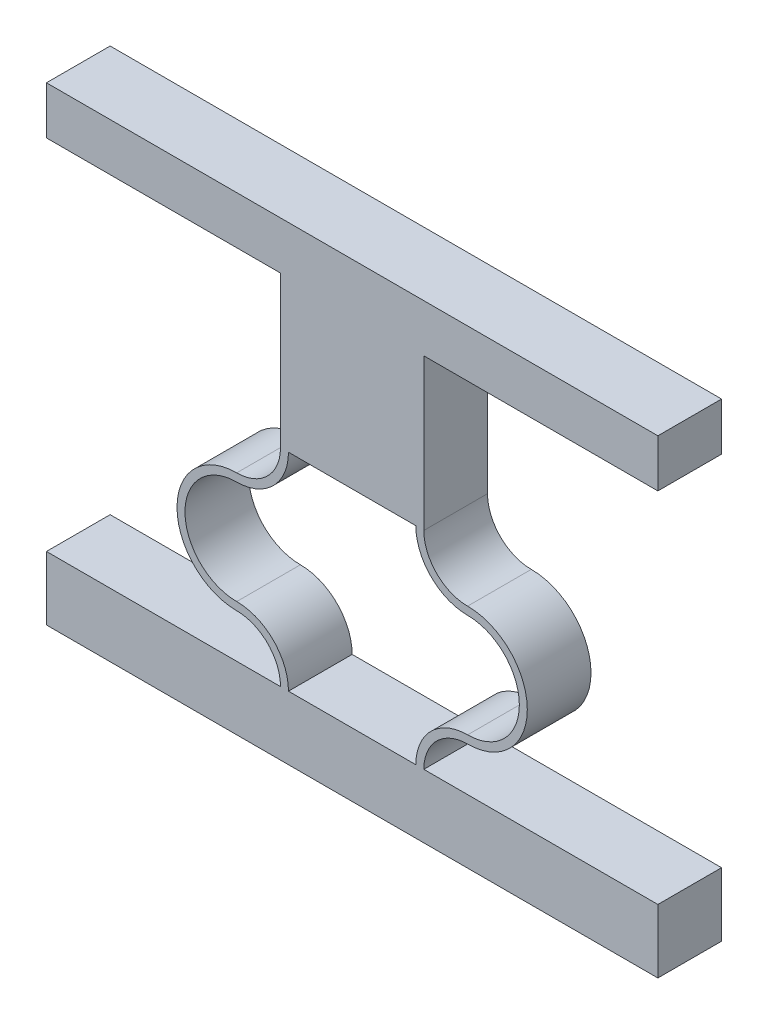
from build123d import *

# Parameters (mm, degrees)
BOSS_EXTRUDE1_DEPTH = 4
SKETCH4_W           = 1.000028655
SKETCH4_H           = 4
BOSS_EXTRUDE2_DEPTH = 1.5
SKETCH7_W           = 4
SKETCH7_H           = 4.491123012
SKETCH7_H_2         = 4
BOSS_EXTRUDE3_DEPTH = 4
MOVE_FACE1_BY       = 5
SKETCH8_W           = 38.400000218
SKETCH8_H           = 3
BOSS_EXTRUDE4_DEPTH = 4
CUT_EXTRUDE1_DEPTH  = 37.207145202
SKETCH11_W          = 5.000000006
SKETCH11_H          = 13.249999512
SKETCH11_W_2        = 5.000000005
CUT_EXTRUDE2_DEPTH  = 37.20714505


with BuildPart() as part:
    # Sketch1 → Boss-Extrude1 (new body)
    with BuildSketch(Plane.XY):
        with BuildLine():
            add(Edge.make_bspline(
                [(10.700014224, 14.741123012), (10.769414318, 14.738663695), (11.03310814, 14.727603281), (11.490614063, 14.697170592), (12.262749669, 14.614202549), (13.344934017, 14.437909286), (14.416347819, 14.207015891), (15.483183095, 13.956131655), (16.319838847, 13.766249034), (16.857815383, 13.652304096), (17.362886901, 13.553302991), (17.776414428, 13.479790745), (18.203500731, 13.412396588), (18.656257538, 13.353987061), (18.987768381, 13.3179099), (19.289919617, 13.293036934), (19.513652899, 13.276508776), (19.742348402, 13.265861771), (19.917436469, 13.255829602), (20.20131205, 13.251344917), (20.318835942, 13.249999512), (20.4, 13.249999512)],
                knots=[0.520196639, 0.520196639, 0.520196639, 0.520196639, 0.520196639, 0.53141408, 0.562828159, 0.594242235, 0.645597029, 0.708425214, 0.739839305, 0.771253396, 0.784217346, 0.797181296, 0.823109196, 0.838816246, 0.854523296, 0.870230336, 0.878083855, 0.885937375, 0.893790894, 0.901644413, 0.917351451, 0.917351451, 0.917351451, 0.917351451, 0.917351451], degree=4))
            Line((10.700014224, 14.741123012), (10.700014224, 15.991123012))
            Line((10.700014224, 15.991123012), (9.699985569, 15.991123012))
            Line((9.699985569, 15.991123012), (9.699985569, 14.741123012))
            add(Edge.make_bspline(
                [(0, 13.249999512), (0.081164058, 13.249999512), (0.199729304, 13.251344907), (0.473779629, 13.255829663), (0.709191365, 13.267868104), (1.033438356, 13.285149543), (1.35158977, 13.312755641), (1.750162777, 13.353987577), (2.192328474, 13.412395709), (2.7057608, 13.49221948), (3.305792882, 13.602949191), (4.002230953, 13.748490017), (4.916593693, 13.956132269), (5.983810028, 14.207015465), (7.054976456, 14.437909533), (8.137289789, 14.614202431), (8.909375138, 14.697170645), (9.366886361, 14.727603295), (9.630584373, 14.738663696), (9.699985569, 14.741123012)],
                knots=[0.082648549, 0.082648549, 0.082648549, 0.082648549, 0.082648549, 0.098355587, 0.106209106, 0.114062625, 0.129769664, 0.145476704, 0.161183754, 0.176890804, 0.202818704, 0.228746604, 0.260160695, 0.291574786, 0.354402971, 0.405757765, 0.437171841, 0.46858592, 0.479803371, 0.479803371, 0.479803371, 0.479803371, 0.479803371], degree=4))
            Line((0, 13.249999512), (-5.000000005, 13.249999512))
            Line((-5.000000005, 13.249999512), (-5.000000005, -4))
            Line((-5.000000005, -4), (25.400000005, -4))
            Line((25.400000005, -4), (25.400000005, 13.249999512))
            Line((25.400000005, 13.249999512), (20.4, 13.249999512))
        make_face()
        with BuildLine():
            Line((9.699985569, 14.491123012), (9.699985569, 13.241123012))
            add(Edge.make_bspline(
                [(0, 11.749999512), (0.081164058, 11.749999512), (0.199729304, 11.751344907), (0.473779629, 11.755829663), (0.709191365, 11.767868104), (1.033438356, 11.785149543), (1.35158977, 11.812755641), (1.750162777, 11.853987577), (2.192328474, 11.912395709), (2.7057608, 11.99221948), (3.305792882, 12.102949191), (4.002230953, 12.248490017), (4.916593693, 12.456132269), (5.983810028, 12.707015465), (7.054976456, 12.937909533), (8.137289789, 13.114202431), (8.909375138, 13.197170645), (9.366886361, 13.227603295), (9.630584373, 13.238663696), (9.699985569, 13.241123012)],
                knots=[0.082648549, 0.082648549, 0.082648549, 0.082648549, 0.082648549, 0.098355587, 0.106209106, 0.114062625, 0.129769664, 0.145476704, 0.161183754, 0.176890804, 0.202818704, 0.228746604, 0.260160695, 0.291574786, 0.354402971, 0.405757765, 0.437171841, 0.46858592, 0.479803371, 0.479803371, 0.479803371, 0.479803371, 0.479803371], degree=4))
            Line((0, 11.749999512), (0, 12.999999512))
            add(Edge.make_bspline(
                [(0, 12.999999512), (0.081164058, 12.999999512), (0.199729304, 13.001344907), (0.473779629, 13.005829663), (0.709191365, 13.017868104), (1.033438356, 13.035149543), (1.35158977, 13.062755641), (1.750162777, 13.103987577), (2.192328474, 13.162395709), (2.7057608, 13.24221948), (3.305792882, 13.352949191), (4.002230953, 13.498490017), (4.916593693, 13.706132269), (5.983810028, 13.957015465), (7.054976456, 14.187909533), (8.137289789, 14.364202431), (8.909375138, 14.447170645), (9.366886361, 14.477603295), (9.630584373, 14.488663696), (9.699985569, 14.491123012)],
                knots=[0.082648549, 0.082648549, 0.082648549, 0.082648549, 0.082648549, 0.098355587, 0.106209106, 0.114062625, 0.129769664, 0.145476704, 0.161183754, 0.176890804, 0.202818704, 0.228746604, 0.260160695, 0.291574786, 0.354402971, 0.405757765, 0.437171841, 0.46858592, 0.479803371, 0.479803371, 0.479803371, 0.479803371, 0.479803371], degree=4))
        make_face(mode=Mode.SUBTRACT)
        with BuildLine():
            Line((10.700014224, 13.241123012), (10.700014224, 14.491123012))
            add(Edge.make_bspline(
                [(10.700014224, 14.491123012), (10.769414318, 14.488663695), (11.03310814, 14.477603281), (11.490614063, 14.447170592), (12.262749669, 14.364202549), (13.344934017, 14.187909286), (14.416347819, 13.957015891), (15.483183095, 13.706131655), (16.319838847, 13.516249034), (16.857815383, 13.402304096), (17.362886901, 13.303302991), (17.776414428, 13.229790745), (18.203500731, 13.162396588), (18.656257538, 13.103987061), (18.987768381, 13.0679099), (19.289919617, 13.043036934), (19.513652899, 13.026508776), (19.742348402, 13.015861771), (19.917436469, 13.005829602), (20.20131205, 13.001344917), (20.318835942, 12.999999512), (20.4, 12.999999512)],
                knots=[0.520196639, 0.520196639, 0.520196639, 0.520196639, 0.520196639, 0.53141408, 0.562828159, 0.594242235, 0.645597029, 0.708425214, 0.739839305, 0.771253396, 0.784217346, 0.797181296, 0.823109196, 0.838816246, 0.854523296, 0.870230336, 0.878083855, 0.885937375, 0.893790894, 0.901644413, 0.917351451, 0.917351451, 0.917351451, 0.917351451, 0.917351451], degree=4))
            Line((20.4, 12.999999512), (20.4, 11.749999512))
            add(Edge.make_bspline(
                [(10.700014224, 13.241123012), (10.769414318, 13.238663695), (11.03310814, 13.227603281), (11.490614063, 13.197170592), (12.262749669, 13.114202549), (13.344934017, 12.937909286), (14.416347819, 12.707015891), (15.483183095, 12.456131655), (16.319838847, 12.266249034), (16.857815383, 12.152304096), (17.362886901, 12.053302991), (17.776414428, 11.979790745), (18.203500731, 11.912396588), (18.656257538, 11.853987061), (18.987768381, 11.8179099), (19.289919617, 11.793036934), (19.513652899, 11.776508776), (19.742348402, 11.765861771), (19.917436469, 11.755829602), (20.20131205, 11.751344917), (20.318835942, 11.749999512), (20.4, 11.749999512)],
                knots=[0.520196639, 0.520196639, 0.520196639, 0.520196639, 0.520196639, 0.53141408, 0.562828159, 0.594242235, 0.645597029, 0.708425214, 0.739839305, 0.771253396, 0.784217346, 0.797181296, 0.823109196, 0.838816246, 0.854523296, 0.870230336, 0.878083855, 0.885937375, 0.893790894, 0.901644413, 0.917351451, 0.917351451, 0.917351451, 0.917351451, 0.917351451], degree=4))
        make_face(mode=Mode.SUBTRACT)
        with BuildLine():
            Line((0, 0), (0, 11.499999512))
            add(Edge.make_bspline(
                [(0, 11.499999512), (0.081164058, 11.499999512), (0.199729304, 11.501344907), (0.473779629, 11.505829663), (0.709191365, 11.517868104), (1.033438356, 11.535149543), (1.35158977, 11.562755641), (1.750162777, 11.603987577), (2.192328474, 11.662395709), (2.7057608, 11.74221948), (3.305792882, 11.852949191), (4.002230953, 11.998490017), (4.916593693, 12.206132269), (5.983810028, 12.457015465), (7.054976456, 12.687909533), (8.137289789, 12.864202431), (8.909375138, 12.947170645), (9.366886361, 12.977603295), (9.630584373, 12.988663696), (9.699985569, 12.991123012)],
                knots=[0.082648549, 0.082648549, 0.082648549, 0.082648549, 0.082648549, 0.098355587, 0.106209106, 0.114062625, 0.129769664, 0.145476704, 0.161183754, 0.176890804, 0.202818704, 0.228746604, 0.260160695, 0.291574786, 0.354402971, 0.405757765, 0.437171841, 0.46858592, 0.479803371, 0.479803371, 0.479803371, 0.479803371, 0.479803371], degree=4))
            ThreePointArc((9.699985569, 12.991123012), (8.891402518, 11.052320391), (6.949999896, 10.25))
            ThreePointArc((6.949999896, 10.25), (3.199999896, 6.5), (6.949999896, 2.75))
            ThreePointArc((6.949999896, 2.75), (8.894543545, 1.944543648), (9.699999896, 0))
            Line((9.699999896, 0), (0, 0))
        make_face(mode=Mode.SUBTRACT)
        with BuildLine():
            ThreePointArc((6.949999896, 9.75), (9.248096935, 10.701902961), (10.199999896, 13))
            ThreePointArc((10.199999896, 13), (11.151902857, 10.701902961), (13.449999896, 9.75))
            ThreePointArc((13.449999896, 9.75), (16.699999896, 6.5), (13.449999896, 3.25))
            ThreePointArc((13.449999896, 3.25), (11.151902857, 2.298097039), (10.199999896, 0))
            ThreePointArc((10.199999896, 0), (9.248096935, 2.298097039), (6.949999896, 3.25))
            ThreePointArc((6.949999896, 3.25), (3.699999896, 6.5), (6.949999896, 9.75))
        make_face(mode=Mode.SUBTRACT)
        with BuildLine():
            ThreePointArc((13.449999896, 10.25), (11.508597274, 11.052320391), (10.700014224, 12.991123012))
            add(Edge.make_bspline(
                [(10.700014224, 12.991123012), (10.769414318, 12.988663695), (11.03310814, 12.977603281), (11.490614063, 12.947170592), (12.262749669, 12.864202549), (13.344934017, 12.687909286), (14.416347819, 12.457015891), (15.483183095, 12.206131655), (16.319838847, 12.016249034), (16.857815383, 11.902304096), (17.362886901, 11.803302991), (17.776414428, 11.729790745), (18.203500731, 11.662396588), (18.656257538, 11.603987061), (18.987768381, 11.5679099), (19.289919617, 11.543036934), (19.513652899, 11.526508776), (19.742348402, 11.515861771), (19.917436469, 11.505829602), (20.20131205, 11.501344917), (20.318835942, 11.499999512), (20.4, 11.499999512)],
                knots=[0.520196639, 0.520196639, 0.520196639, 0.520196639, 0.520196639, 0.53141408, 0.562828159, 0.594242235, 0.645597029, 0.708425214, 0.739839305, 0.771253396, 0.784217346, 0.797181296, 0.823109196, 0.838816246, 0.854523296, 0.870230336, 0.878083855, 0.885937375, 0.893790894, 0.901644413, 0.917351451, 0.917351451, 0.917351451, 0.917351451, 0.917351451], degree=4))
            Line((20.4, 11.499999512), (20.4, 0))
            Line((20.4, 0), (10.699999896, 0))
            ThreePointArc((10.699999896, 0), (11.505456248, 1.944543648), (13.449999896, 2.75))
            ThreePointArc((13.449999896, 2.75), (17.199999896, 6.5), (13.449999896, 10.25))
        make_face(mode=Mode.SUBTRACT)
    extrude(amount=BOSS_EXTRUDE1_DEPTH)

    # Sketch4 → Boss-Extrude2 (add)
    with BuildSketch(Plane(origin=(0, 15.991123012, 0), x_dir=(1, 0, 0), z_dir=(0, 1, 0))):
        with Locations((10.199999896, -2)):
            Rectangle(SKETCH4_W, SKETCH4_H)
    extrude(amount=BOSS_EXTRUDE2_DEPTH)

    # Split2
    split(bisect_by=Plane(origin=(10.199999896, 0, 0), x_dir=(0, -1, 0), z_dir=(-1, 0, 0)), keep=Keep.BOTTOM)

    # Sketch7 → Boss-Extrude3 (add)
    with BuildSketch(Plane.ZY.offset(-10.199999896)):
        with Locations((2, 15.245561506)):
            Rectangle(SKETCH7_W, SKETCH7_H)
        with Locations((2, -2)):
            Rectangle(SKETCH7_W, SKETCH7_H_2)
    extrude(amount=BOSS_EXTRUDE3_DEPTH)

    # Mirror2: part across plane


with BuildPart() as part_1:
    add(part.part)
    add(part.part.mirror(Plane.ZY.offset(-6.199999896)))

    # Move Face1: a face moved outward by 5.0
    extrude(part_1.faces().sort_by_distance((6.199999896, 17.491123012, 2))[0], amount=MOVE_FACE1_BY, dir=(0, 1, 0))

    # Sketch8 → Boss-Extrude4 (add)
    with BuildSketch(Plane.XY.offset(4)):
        with Locations((6.199999896, 23.991123012)):
            Rectangle(SKETCH8_W, SKETCH8_H)
    extrude(amount=-BOSS_EXTRUDE4_DEPTH)

    # Sketch10 → Cut-Extrude1 (cut, through all)
    with BuildSketch(Plane.XY.offset(4)):
        Polygon((10.700014224, 12.991123012), (10.700014224, 13.241123012), (10.700014224, 14.491123012), (10.700014224, 14.741123012), (20.4, 14.741123012), (20.4, 11.499999512), (15.435396156, 11.499999512), align=None)
        with BuildLine():
            Line((1.699985569, 14.491123012), (1.699985569, 14.741123012))
            add(Edge.make_bspline(
                [(1.699985569, 14.741123012), (1.630585475, 14.738663695), (1.366891652, 14.727603281), (0.909385729, 14.697170592), (0.137250123, 14.614202549), (-0.944934224, 14.437909286), (-2.016348027, 14.207015891), (-3.083183302, 13.956131655), (-3.919839055, 13.766249034), (-4.45781559, 13.652304096), (-4.962887108, 13.553302991), (-5.376414636, 13.479790745), (-5.803500939, 13.412396588), (-6.256257745, 13.353987061), (-6.587768589, 13.3179099), (-6.889919824, 13.293036934), (-7.113653107, 13.276508776), (-7.342348609, 13.265861771), (-7.517436676, 13.255829602), (-7.801312257, 13.251344917), (-7.91883615, 13.249999512), (-8.000000207, 13.249999512)],
                knots=[0.520196639, 0.520196639, 0.520196639, 0.520196639, 0.520196639, 0.53141408, 0.562828159, 0.594242235, 0.645597029, 0.708425214, 0.739839305, 0.771253396, 0.784217346, 0.797181296, 0.823109196, 0.838816246, 0.854523296, 0.870230336, 0.878083855, 0.885937375, 0.893790894, 0.901644413, 0.917351451, 0.917351451, 0.917351451, 0.917351451, 0.917351451], degree=4))
            Line((-8.000000207, 13.249999512), (-8.000000207, 12.999999512))
            add(Edge.make_bspline(
                [(1.699985569, 14.491123012), (1.630585475, 14.488663695), (1.366891652, 14.477603281), (0.909385729, 14.447170592), (0.137250123, 14.364202549), (-0.944934224, 14.187909286), (-2.016348027, 13.957015891), (-3.083183302, 13.706131655), (-3.919839055, 13.516249034), (-4.45781559, 13.402304096), (-4.962887108, 13.303302991), (-5.376414636, 13.229790745), (-5.803500939, 13.162396588), (-6.256257745, 13.103987061), (-6.587768589, 13.0679099), (-6.889919824, 13.043036934), (-7.113653107, 13.026508776), (-7.342348609, 13.015861771), (-7.517436676, 13.005829602), (-7.801312257, 13.001344917), (-7.91883615, 12.999999512), (-8.000000207, 12.999999512)],
                knots=[0.520196639, 0.520196639, 0.520196639, 0.520196639, 0.520196639, 0.53141408, 0.562828159, 0.594242235, 0.645597029, 0.708425214, 0.739839305, 0.771253396, 0.784217346, 0.797181296, 0.823109196, 0.838816246, 0.854523296, 0.870230336, 0.878083855, 0.885937375, 0.893790894, 0.901644413, 0.917351451, 0.917351451, 0.917351451, 0.917351451, 0.917351451], degree=4))
        make_face()
        with BuildLine():
            Line((1.699985569, 12.991123012), (1.699985569, 13.241123012))
            add(Edge.make_bspline(
                [(1.699985569, 13.241123012), (1.630585475, 13.238663695), (1.366891652, 13.227603281), (0.909385729, 13.197170592), (0.137250123, 13.114202549), (-0.944934224, 12.937909286), (-2.016348027, 12.707015891), (-3.083183302, 12.456131655), (-3.919839055, 12.266249034), (-4.45781559, 12.152304096), (-4.962887108, 12.053302991), (-5.376414636, 11.979790745), (-5.803500939, 11.912396588), (-6.256257745, 11.853987061), (-6.587768589, 11.8179099), (-6.889919824, 11.793036934), (-7.113653107, 11.776508776), (-7.342348609, 11.765861771), (-7.517436676, 11.755829602), (-7.801312257, 11.751344917), (-7.91883615, 11.749999512), (-8.000000207, 11.749999512)],
                knots=[0.520196639, 0.520196639, 0.520196639, 0.520196639, 0.520196639, 0.53141408, 0.562828159, 0.594242235, 0.645597029, 0.708425214, 0.739839305, 0.771253396, 0.784217346, 0.797181296, 0.823109196, 0.838816246, 0.854523296, 0.870230336, 0.878083855, 0.885937375, 0.893790894, 0.901644413, 0.917351451, 0.917351451, 0.917351451, 0.917351451, 0.917351451], degree=4))
            Line((-8.000000207, 11.749999512), (-8.000000207, 11.499999512))
            add(Edge.make_bspline(
                [(1.699985569, 12.991123012), (1.630585475, 12.988663695), (1.366891652, 12.977603281), (0.909385729, 12.947170592), (0.137250123, 12.864202549), (-0.944934224, 12.687909286), (-2.016348027, 12.457015891), (-3.083183302, 12.206131655), (-3.919839055, 12.016249034), (-4.45781559, 11.902304096), (-4.962887108, 11.803302991), (-5.376414636, 11.729790745), (-5.803500939, 11.662396588), (-6.256257745, 11.603987061), (-6.587768589, 11.5679099), (-6.889919824, 11.543036934), (-7.113653107, 11.526508776), (-7.342348609, 11.515861771), (-7.517436676, 11.505829602), (-7.801312257, 11.501344917), (-7.91883615, 11.499999512), (-8.000000207, 11.499999512)],
                knots=[0.520196639, 0.520196639, 0.520196639, 0.520196639, 0.520196639, 0.53141408, 0.562828159, 0.594242235, 0.645597029, 0.708425214, 0.739839305, 0.771253396, 0.784217346, 0.797181296, 0.823109196, 0.838816246, 0.854523296, 0.870230336, 0.878083855, 0.885937375, 0.893790894, 0.901644413, 0.917351451, 0.917351451, 0.917351451, 0.917351451, 0.917351451], degree=4))
        make_face()
    extrude(amount=-CUT_EXTRUDE1_DEPTH, mode=Mode.SUBTRACT)

    # Sketch11 → Cut-Extrude2 (cut, through all)
    with BuildSketch(Plane.XY.offset(4)):
        with Locations((-10.50000021, 6.624999756)):
            Rectangle(SKETCH11_W, SKETCH11_H)
        with Locations((22.900000003, 6.624999756)):
            Rectangle(SKETCH11_W_2, SKETCH11_H)
    extrude(amount=-CUT_EXTRUDE2_DEPTH, mode=Mode.SUBTRACT)


solid = part_1.part
